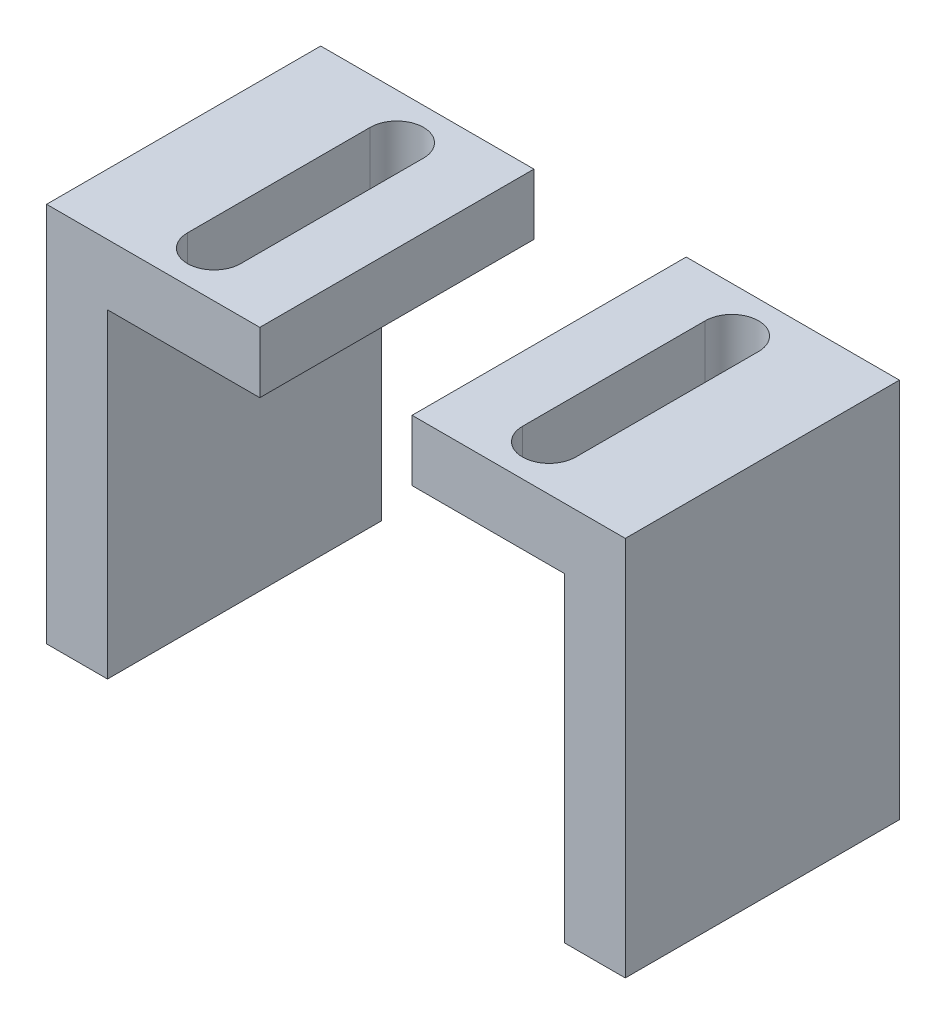
from build123d import *

# Parameters (mm, degrees)
BOSS_EXTRUDE1_DEPTH = 18
CUT_EXTRUDE1_DEPTH  = 18


with BuildPart() as part:
    # Sketch2 → Boss-Extrude1 (new body)
    with BuildSketch(Plane.XY):
        Polygon((0, 0), (-10, 0), (-10, -21), (-14, -21), (-14, 4), (0, 4), align=None)
    extrude(amount=BOSS_EXTRUDE1_DEPTH)

    # Sketch3 → Cut-Extrude1 (cut)
    with BuildSketch(Plane(origin=(0, 4, 0), x_dir=(1, 0, 0), z_dir=(0, 1, 0))):
        with BuildLine():
            Line((-4.25, -3), (-4.25, -15))
            ThreePointArc((-4.25, -15), (-6, -16.75), (-7.75, -15))
            Line((-7.75, -15), (-7.75, -3))
            ThreePointArc((-7.75, -3), (-6, -1.25), (-4.25, -3))
        make_face()
    extrude(amount=-CUT_EXTRUDE1_DEPTH, mode=Mode.SUBTRACT)


with BuildPart() as body_2:
    # Mirror2: mirrored copy
    add(part.part.mirror(Plane(origin=(5, 0, 0), x_dir=(0, 0, 1), z_dir=(1, 0, 0))))


solid = Compound([part.part, body_2.part])
